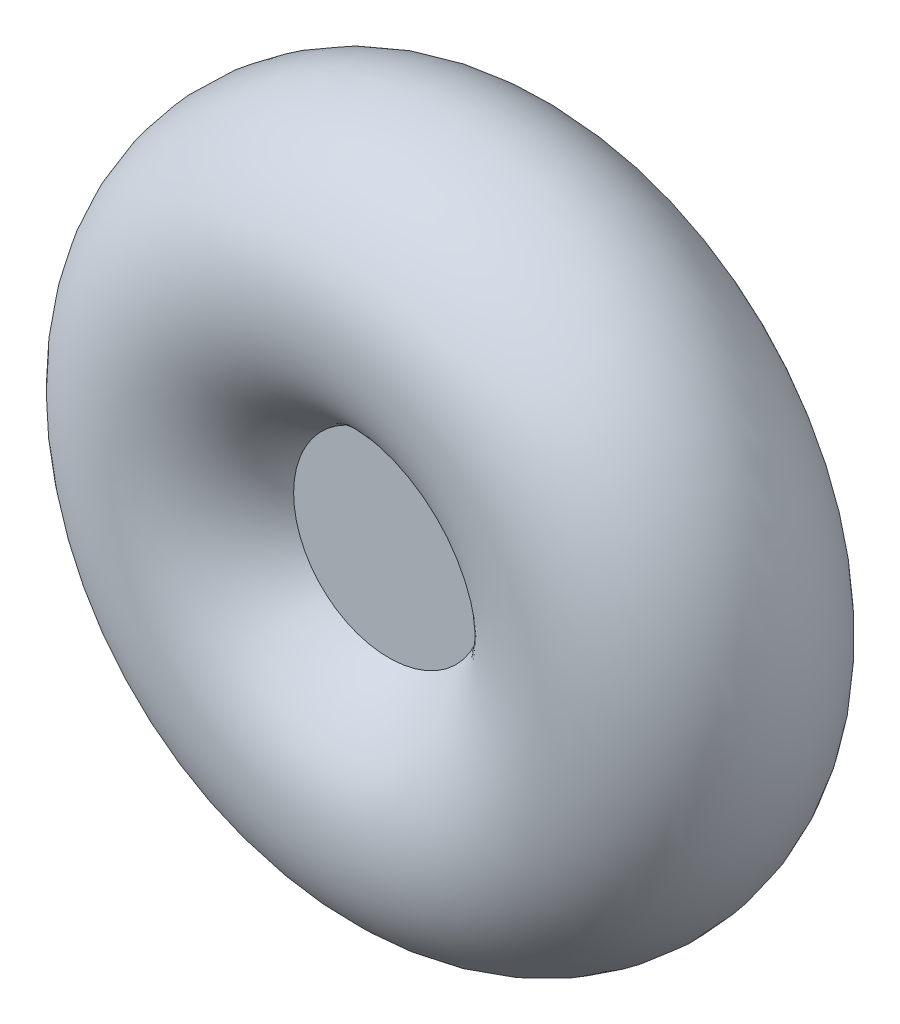
from build123d import *


with BuildPart() as part:
    # Sketch1 → Revolve1 (revolve)
    with BuildSketch(Plane(origin=(0, 0, 0), x_dir=(0, 0, -1), z_dir=(1, 0, 0))):
        with BuildLine():
            ThreePointArc((20.765508886, 33.209491114), (-10.813735982, 50.937138262), (-9.502901594, 14.745980598))
            Line((-9.502901594, 14.745980598), (9.502901594, 14.745980598))
            ThreePointArc((9.502901594, 14.745980598), (17.727647147, 22.395755132), (20.765508886, 33.209491114))
        make_face()
        with BuildLine():
            Line((9.502901594, 14.745980598), (-9.502901594, 14.745980598))
            ThreePointArc((-9.502901594, 14.745980598), (0, 12.443982229), (9.502901594, 14.745980598))
        make_face()
        with BuildLine():
            Line((-9.502901594, 14.745980598), (-9.502901594, 0))
            Line((-9.502901594, 0), (9.502901594, 0))
            Line((9.502901594, 0), (9.502901594, 14.745980598))
            ThreePointArc((9.502901594, 14.745980598), (0, 12.443982229), (-9.502901594, 14.745980598))
        make_face()
    revolve(axis=Axis((0, 0, 0), (0, 0, 1)))


solid = part.part
